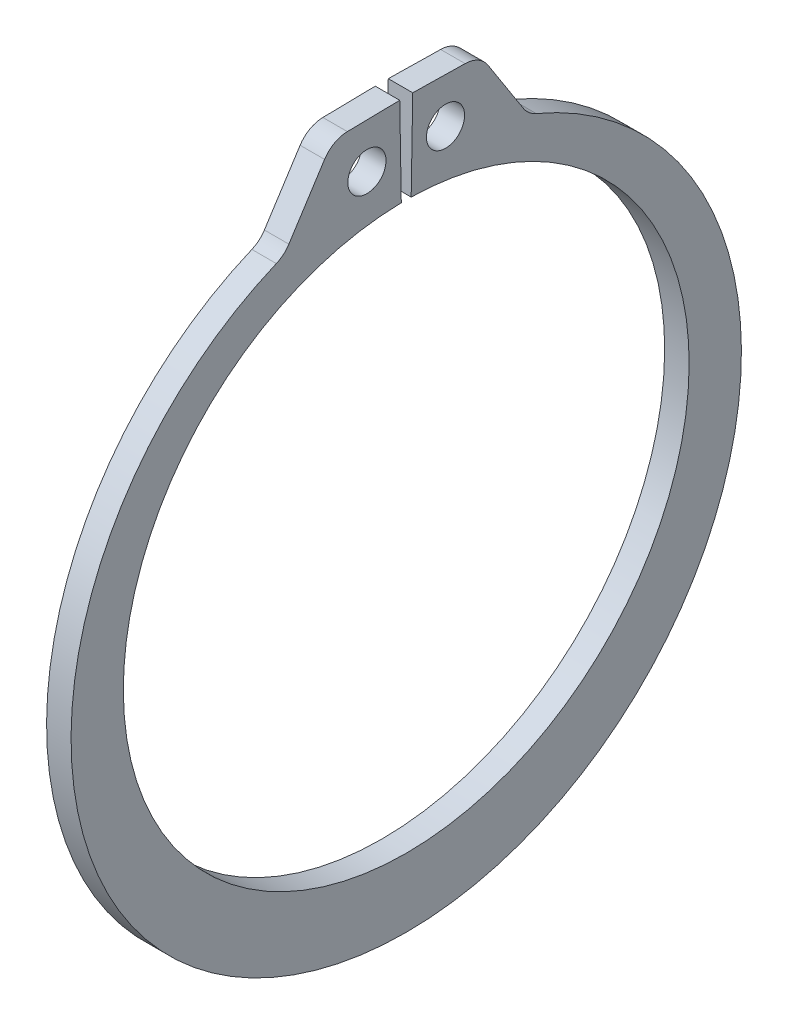
from build123d import *

# Parameters (mm, degrees)
SKETCH1_R      = 0.9906
EXTRUDE1_DEPTH = 0.635
FILLET1_R      = 1.4351


with BuildPart() as part:
    # Sketch1 → Extrude1 (new body, symmetric)
    with BuildSketch(Plane(origin=(0, 0, 0), x_dir=(0, 0, -1), z_dir=(1, 0, 0))):
        with BuildLine():
            Line((-0.256222269, 14.678963982), (-0.337344545, 19.326456039))
            Line((-0.337344545, 19.326456039), (-3.822963587, 19.265614332))
            Line((-3.822963587, 19.265614332), (-6.336448705, 15.355607196))
            ThreePointArc((-6.336448705, 15.355607196), (0, -18.2372), (6.336448705, 15.355607196))
            Line((6.336448705, 15.355607196), (3.822963587, 19.265614332))
            Line((3.822963587, 19.265614332), (0.337344545, 19.326456039))
            Line((0.337344545, 19.326456039), (0.256222269, 14.678963982))
            ThreePointArc((0.256222269, 14.678963982), (0, -14.6812), (-0.256222269, 14.678963982))
        make_face()
        with Locations((-2.039592928, 16.972289157)):
            Circle(SKETCH1_R, mode=Mode.SUBTRACT)
        with Locations((2.039592928, 16.972289157)):
            Circle(SKETCH1_R, mode=Mode.SUBTRACT)
    extrude(amount=EXTRUDE1_DEPTH, both=True)

    # Fillet1
    fillet1_edges = [part.edges().sort_by_distance(p)[0] for p in [
        (0, 19.265614332, -3.822963587),
        (0, 15.355607196, -6.336448705),
        (0, 15.355607196, 6.336448705),
        (0, 19.265614332, 3.822963587),
    ]]
    fillet(fillet1_edges, radius=FILLET1_R)


solid = part.part
